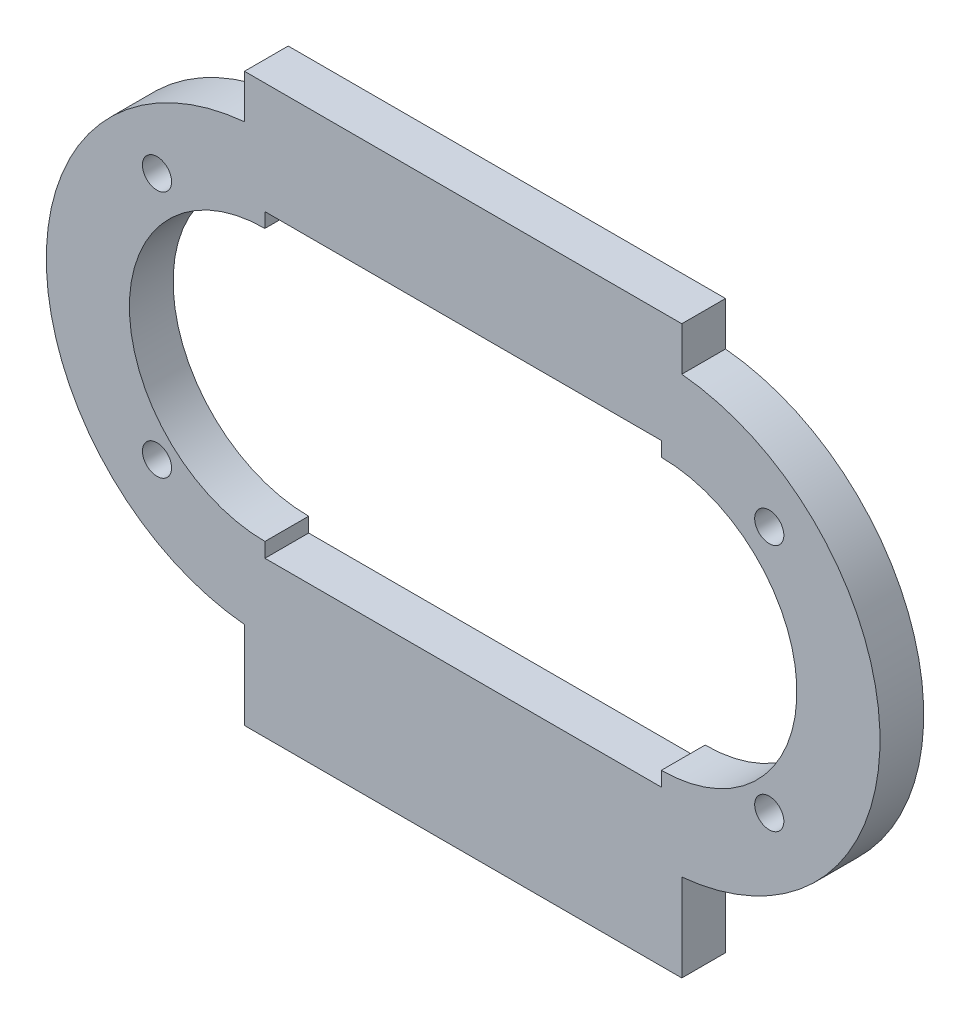
from build123d import *

# Parameters (mm, degrees)
CROQUIS1_R              = 1
SALIENTE_EXTRUIR1_DEPTH = 3


with BuildPart() as part:
    # Croquis1 → Saliente-Extruir1 (new body)
    with BuildSketch(Plane.XY):
        with BuildLine():
            Line((28.59683313, -20.934226553), (28.59683313, -14.934226553))
            ThreePointArc((28.59683313, -14.934226553), (42.193666261, 0), (28.59683313, 14.934226553))
            Line((28.59683313, 14.934226553), (28.59683313, 17.934226553))
            Line((28.59683313, 17.934226553), (-1.40316687, 17.934226553))
            Line((-1.40316687, 17.934226553), (-1.40316687, 14.934226553))
            ThreePointArc((-1.40316687, 14.934226553), (-15, 0), (-1.40316687, -14.934226553))
            Line((-1.40316687, -14.934226553), (-1.40316687, -20.934226553))
            Line((-1.40316687, -20.934226553), (28.59683313, -20.934226553))
        make_face()
        with Locations((-7.40316687, 8.867372458)):
            Circle(CROQUIS1_R, mode=Mode.SUBTRACT)
        with Locations((34.59683313, 8.867372458)):
            Circle(CROQUIS1_R, mode=Mode.SUBTRACT)
        with Locations((34.59683313, -8.132627542)):
            Circle(CROQUIS1_R, mode=Mode.SUBTRACT)
        with Locations((-7.40316687, -8.132627542)):
            Circle(CROQUIS1_R, mode=Mode.SUBTRACT)
        with BuildLine():
            Line((0, -10.297541691), (27.193666261, -10.297541691))
            Line((27.193666261, -10.297541691), (27.193666261, -9.297541691))
            ThreePointArc((27.193666261, -9.297541691), (36.491207952, 0), (27.193666261, 9.297541691))
            Line((27.193666261, 9.297541691), (27.193666261, 10.297541691))
            Line((27.193666261, 10.297541691), (0, 10.297541691))
            Line((0, 10.297541691), (0, 9.297541691))
            ThreePointArc((0, 9.297541691), (-9.297541691, 0), (0, -9.297541691))
            Line((0, -9.297541691), (0, -10.297541691))
        make_face(mode=Mode.SUBTRACT)
    extrude(amount=SALIENTE_EXTRUIR1_DEPTH)


solid = part.part
